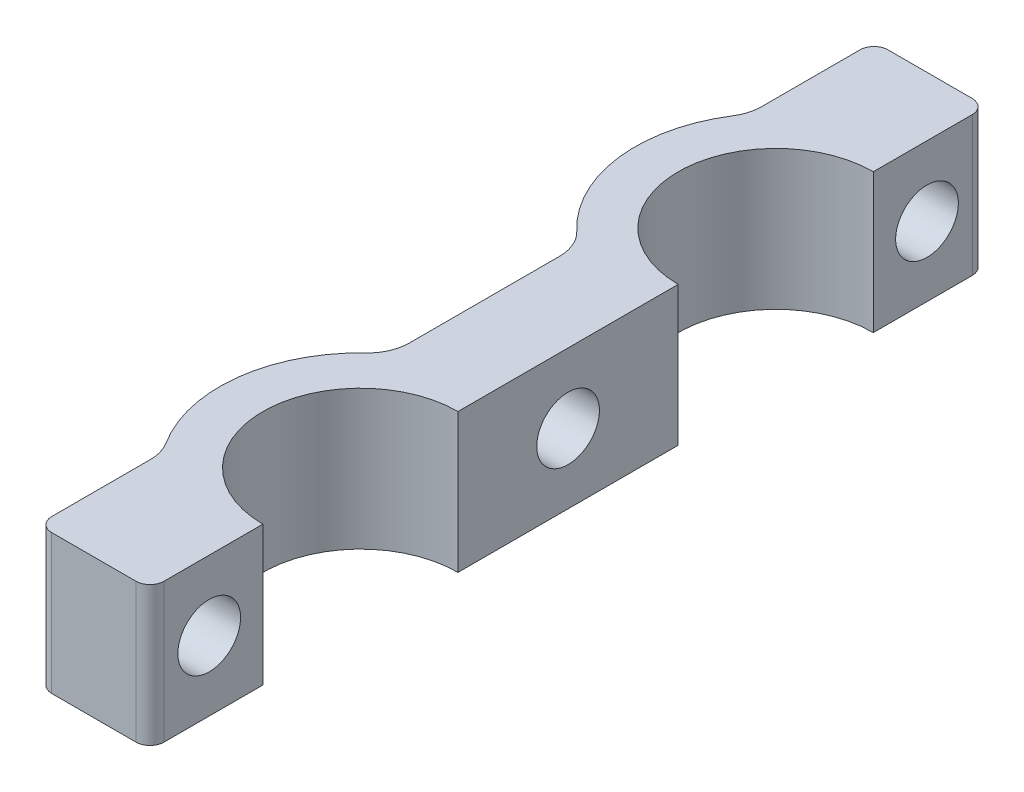
from build123d import *

# Parameters (mm, degrees)
EXTRUDE_1_DEPTH          = 10
EXTRUDE_2_DEPTH          = 10
SKETCH_3_R               = 2.25
CUT_EXTRUDE_1_DEPTH      = 5.049845
CUT_EXTRUDE_1_DEPTH_BACK = 4
EXTRUDE_4_DEPTH          = 10
SKETCH_4_R               = 2.25
CUT_EXTRUDE_2_DEPTH      = 7
FILLET_1_R               = 3
FILLET_2_R               = 1
EXTRUDE_3_DEPTH          = 10
FILLET_3_R               = 1


with BuildPart() as part:
    # Эскиз1 → Бобышка-Вытянуть1 (new body)
    with BuildSketch(Plane(origin=(0, 0, 0), x_dir=(1, 0, 0), z_dir=(0, 1, 0))):
        with BuildLine():
            Line((0, 0), (0, 8))
            ThreePointArc((0, 8), (-7.1, 15.1), (0, 22.2))
            Line((0, 22.2), (0, 37.8))
            ThreePointArc((0, 37.8), (-7.1, 44.9), (0, 52))
            Line((0, 52), (0, 60))
            Line((0, 60), (-3, 60))
            Line((-3, 60), (-3, 54.544169223))
            ThreePointArc((-3, 54.544169223), (-10.1, 44.9), (-3, 35.255830777))
            Line((-3, 35.255830777), (-3, 24.744169223))
            ThreePointArc((-3, 24.744169223), (-10.1, 15.1), (-3, 5.455830777))
            Line((-3, 5.455830777), (-3, 0))
            Line((-3, 0), (0, 0))
        make_face()
    extrude(amount=EXTRUDE_1_DEPTH)

    # Эскиз2 → Бобышка-Вытянуть2 (add)
    with BuildSketch(Plane(origin=(0, 10, 0), x_dir=(1, 0, 0), z_dir=(0, 1, 0))):
        with BuildLine():
            Line((-3, 60), (-8.049844719, 60))
            Line((-8.049844719, 60), (-8.049844719, 51))
            ThreePointArc((-8.049844719, 51), (-5.802159163, 53.167100402), (-3, 54.544169223))
            Line((-3, 54.544169223), (-3, 60))
        make_face()
        with BuildLine():
            Line((-3, 0), (-3, 5.455830777))
            ThreePointArc((-3, 5.455830777), (-5.802159163, 6.832899598), (-8.049844719, 9))
            Line((-8.049844719, 9), (-8.049844719, 0))
            Line((-8.049844719, 0), (-3, 0))
        make_face()
    extrude(amount=-EXTRUDE_2_DEPTH)

    # Эскиз3 → Вырез-Вытянуть1 (cut, two sides)
    with BuildSketch(Plane.ZY.offset(3)) as cut_extrude_1_sk:
        with Locations((-55.75, 5)):
            Circle(SKETCH_3_R)
        with Locations((-4.25, 5)):
            Circle(SKETCH_3_R)
    extrude(amount=CUT_EXTRUDE_1_DEPTH, mode=Mode.SUBTRACT)
    extrude(cut_extrude_1_sk.sketch, amount=-CUT_EXTRUDE_1_DEPTH_BACK, mode=Mode.SUBTRACT)

    # Эскиз7 → Бобышка-Вытянуть4 (add, through all)
    with BuildSketch(Plane(origin=(-3, 0, 0), x_dir=(0, 0, 1), z_dir=(0, 1, 0))):
        with BuildLine():
            Line((-36.775346161, -3), (-23.224653839, -3))
            ThreePointArc((-23.224653839, -3), (-24.11014807, -1.563686202), (-24.744169223, 0))
            Line((-24.744169223, 0), (-35.255830777, 0))
            ThreePointArc((-35.255830777, 0), (-35.88985193, -1.563686202), (-36.775346161, -3))
        make_face()
    extrude(amount=EXTRUDE_4_DEPTH)

    # Эскиз4 → Вырез-Вытянуть2 (cut, through all)
    with BuildSketch(Plane.ZY.offset(6)):
        with Locations((-30, 5)):
            Circle(SKETCH_4_R)
    extrude(amount=-CUT_EXTRUDE_2_DEPTH, mode=Mode.SUBTRACT)

    # Скругление1
    fillet_1_edges = [part.edges().sort_by_distance(p)[0] for p in [
        (-8.049844719, 5, -51),
        (-8.049844719, 5, -9),
        (-6, 5, -36.775346161),
        (-6, 5, -23.224653839),
    ]]
    fillet(fillet_1_edges, radius=FILLET_1_R)

    # Скругление2
    fillet_2_edges = [part.edges().sort_by_distance(p)[0] for p in [
        (-8.049844719, 5, -60),
        (-8.049844719, 5, 0),
    ]]
    fillet(fillet_2_edges, radius=FILLET_2_R)

    # Эскиз5 → Бобышка-Вытянуть3 (add, through all)
    with BuildSketch(Plane.XZ):
        with BuildLine():
            Line((0, -8), (0, -8.1))
            ThreePointArc((0, -8.1), (-7, -15.1), (0, -22.1))
            Line((0, -22.1), (0, -22.2))
            ThreePointArc((0, -22.2), (-7.1, -15.1), (0, -8))
        make_face()
        with BuildLine():
            Line((0, -51.9), (0, -52))
            ThreePointArc((0, -52), (-7.1, -44.9), (0, -37.8))
            Line((0, -37.8), (0, -37.9))
            ThreePointArc((0, -37.9), (-7, -44.9), (0, -51.9))
        make_face()
    extrude(amount=-EXTRUDE_3_DEPTH)

    # Скругление3
    fillet_3_edges = [part.edges().sort_by_distance(p)[0] for p in [
        (0, 5, -60),
        (0, 5, 0),
    ]]
    fillet(fillet_3_edges, radius=FILLET_3_R)


solid = part.part
